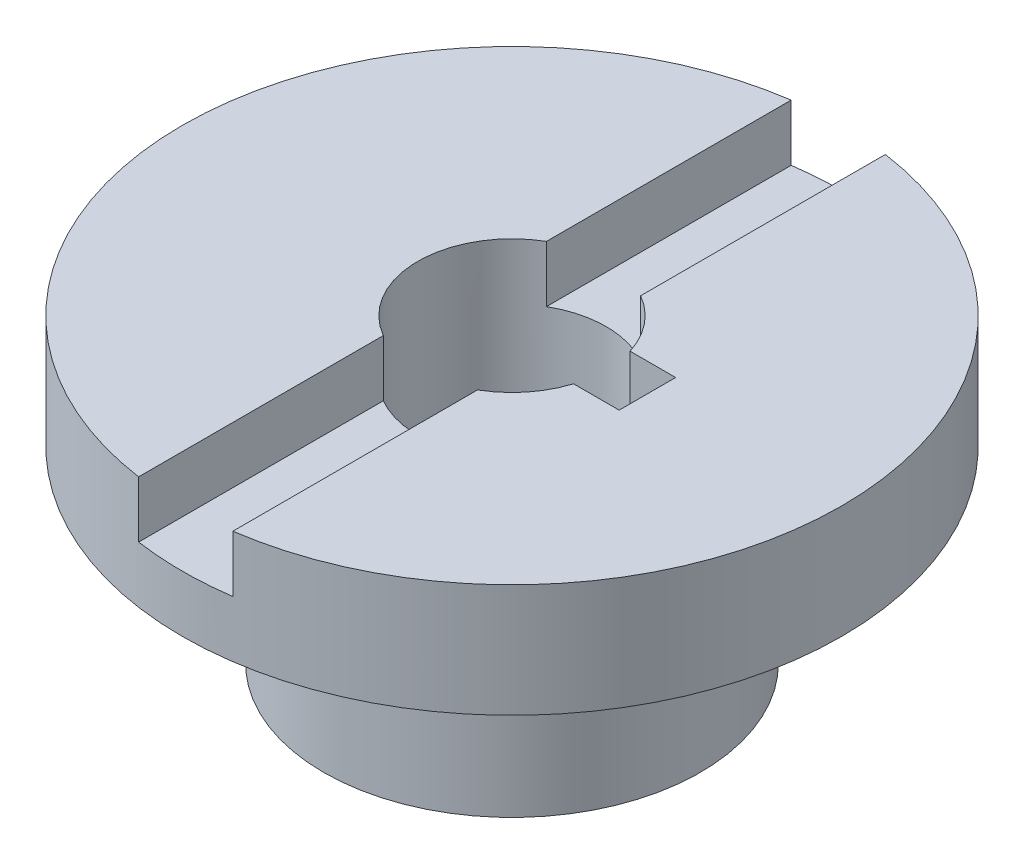
from build123d import *

# Parameters (mm, degrees)
SKETCH1_R               = 10
SKETCH1_R_2             = 5
BOSS_EXTRUDE1_DEPTH     = 10
SKETCH2_R               = 17.5
BOSS_EXTRUDE2_DEPTH     = 6
SKETCH3_W               = 5
SKETCH3_H               = 3
CUT_EXTRUDE1_DEPTH      = 27
CUT_EXTRUDE1_DEPTH_BACK = 20
SKETCH4_R               = 5
CUT_EXTRUDE2_DEPTH      = 20
SKETCH6_W               = 2.522698513
SKETCH6_H               = 3
CUT_EXTRUDE3_DEPTH      = 20


with BuildPart() as part:
    # Sketch1 → Boss-Extrude1 (new body)
    with BuildSketch(Plane(origin=(0, 0, 0), x_dir=(1, 0, 0), z_dir=(0, 1, 0))):
        Circle(SKETCH1_R)
        Circle(SKETCH1_R_2, mode=Mode.SUBTRACT)
    extrude(amount=BOSS_EXTRUDE1_DEPTH)

    # Sketch2 → Boss-Extrude2 (add)
    with BuildSketch(Plane(origin=(0, 10, 0), x_dir=(1, 0, 0), z_dir=(0, 1, 0))):
        Circle(SKETCH2_R)
    extrude(amount=BOSS_EXTRUDE2_DEPTH)

    # Sketch3 → Cut-Extrude1 (cut, two sides)
    with BuildSketch(Plane.XY) as cut_extrude1_sk:
        with Locations((0, 14.5)):
            Rectangle(SKETCH3_W, SKETCH3_H)
    extrude(amount=CUT_EXTRUDE1_DEPTH, mode=Mode.SUBTRACT)
    extrude(cut_extrude1_sk.sketch, amount=-CUT_EXTRUDE1_DEPTH_BACK, mode=Mode.SUBTRACT)

    # Sketch4 → Cut-Extrude2 (cut)
    with BuildSketch(Plane.XZ.offset(-10)):
        Circle(SKETCH4_R)
    extrude(amount=-CUT_EXTRUDE2_DEPTH, mode=Mode.SUBTRACT)

    # Sketch6 → Cut-Extrude3 (cut)
    with BuildSketch(Plane.XZ):
        with Locations((5.927019422, 0)):
            Rectangle(SKETCH6_W, SKETCH6_H)
    extrude(amount=-CUT_EXTRUDE3_DEPTH, mode=Mode.SUBTRACT)


solid = part.part
